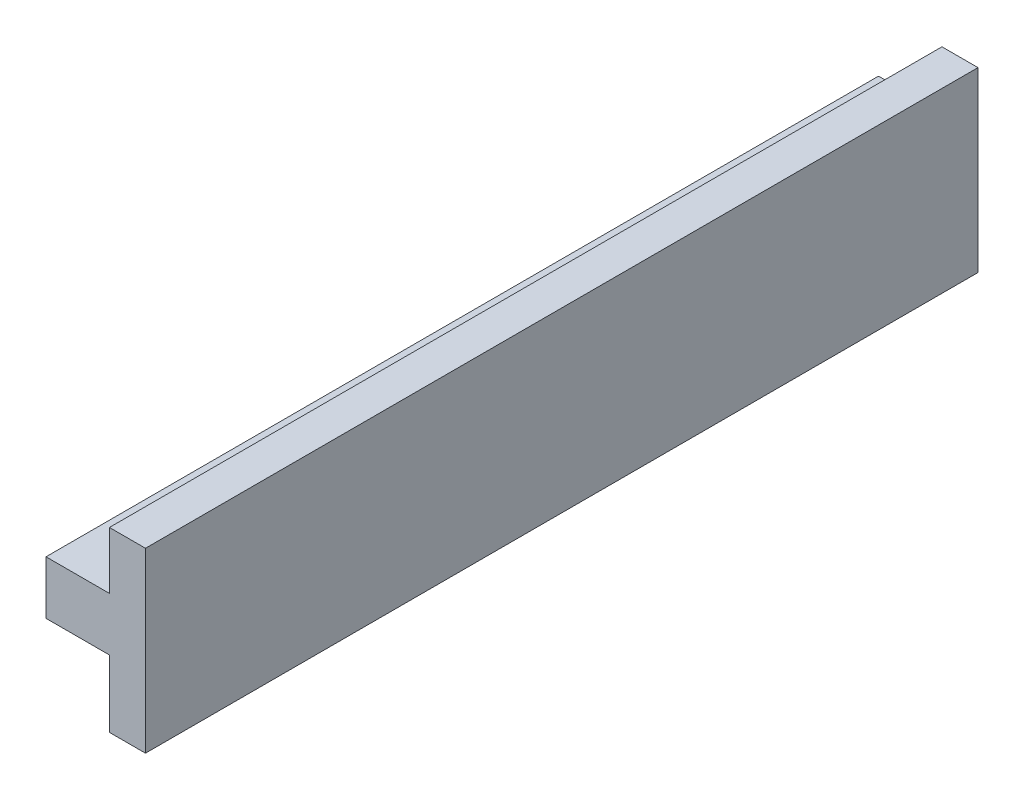
from build123d import *

# Parameters (mm, degrees)
EXTRUDE2_DEPTH = 115.5


with BuildPart() as part:
    # Sketch1 → Extrude2 (new body)
    with BuildSketch(Plane.XY.offset(-35.173777659)):
        Polygon((85.961408719, 43.751957214), (94.761408719, 43.751957214), (94.761408719, 51.676244301), (99.761408719, 51.676244301), (99.761408719, 27.051957214), (94.761408719, 27.051957214), (94.761408719, 36.351957214), (85.961408719, 36.351957214), align=None)
    extrude(amount=-EXTRUDE2_DEPTH)


solid = part.part
